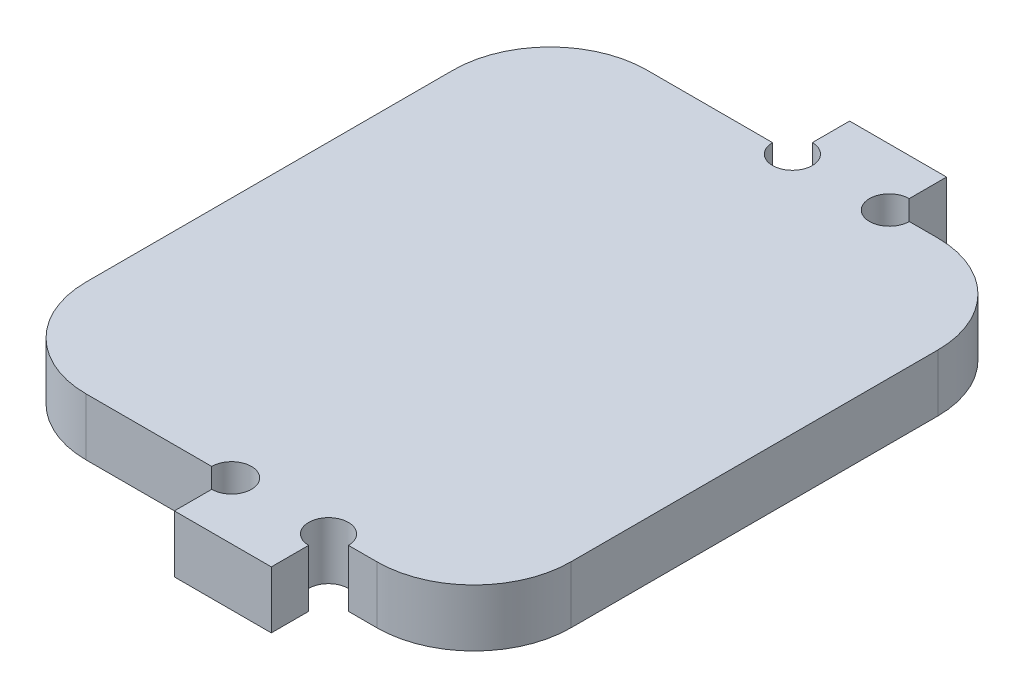
from build123d import *

# Parameters (mm, degrees)
SKETCH1_W           = 10
SKETCH1_H           = 5.9
BOSS_EXTRUDE1_DEPTH = 5.9
FILLET1_R           = 10
CUT_EXTRUDE1_REACH  = 7.9
SKETCH2_R           = 2.05


with BuildPart() as part:
    # Sketch1 → Boss-Extrude1 (new body)
    with BuildSketch(Plane(origin=(0, 0, 0), x_dir=(1, 0, 0), z_dir=(0, 1, 0))):
        Polygon((-25, 28.925), (-25, -28.925), (0, -28.925), (0, -23.025), (10, -23.025), (10, -28.925), (25, -28.925), (25, 28.925), (10, 28.925), (10, 23.025), (0, 23.025), (0, 28.925), align=None)
        with Locations((5, -25.975)):
            Rectangle(SKETCH1_W, SKETCH1_H)
        with Locations((5, -31.875)):
            Rectangle(SKETCH1_W, SKETCH1_H)
        with Locations((5, 25.975)):
            Rectangle(SKETCH1_W, SKETCH1_H)
        with Locations((5, 31.875)):
            Rectangle(SKETCH1_W, SKETCH1_H)
    extrude(amount=BOSS_EXTRUDE1_DEPTH)

    # Fillet1
    fillet1_edges = [part.edges().sort_by_distance(p)[0] for p in [
        (25, 2.95, -28.925),
        (25, 2.95, 28.925),
        (-25, 2.95, 28.925),
        (-25, 2.95, -28.925),
    ]]
    fillet(fillet1_edges, radius=FILLET1_R)

    # Sketch2 → Cut-Extrude1 (cut, up to next)
    with BuildSketch(Plane(origin=(0, 5.9, 0), x_dir=(1, 0, 0), z_dir=(0, 1, 0)), mode=Mode.PRIVATE) as cut_extrude1_sk1:
        with Locations((0, 28.925)):
            Circle(SKETCH2_R)
    cut_extrude1_tool1 = extrude(cut_extrude1_sk1.sketch, amount=-CUT_EXTRUDE1_REACH, mode=Mode.PRIVATE) & part.part
    add(cut_extrude1_tool1.solids().sort_by_distance((0, 5.9, -28.925))[0], mode=Mode.SUBTRACT)
    # Sketch2 → Cut-Extrude1 (cut, up to next)
    with BuildSketch(Plane(origin=(0, 5.9, 0), x_dir=(1, 0, 0), z_dir=(0, 1, 0)), mode=Mode.PRIVATE) as cut_extrude1_sk2:
        with Locations((10, 28.925)):
            Circle(SKETCH2_R)
    cut_extrude1_tool2 = extrude(cut_extrude1_sk2.sketch, amount=-CUT_EXTRUDE1_REACH, mode=Mode.PRIVATE) & part.part
    add(cut_extrude1_tool2.solids().sort_by_distance((10, 5.9, -28.925))[0], mode=Mode.SUBTRACT)
    # Sketch2 → Cut-Extrude1 (cut, up to next)
    with BuildSketch(Plane(origin=(0, 5.9, 0), x_dir=(1, 0, 0), z_dir=(0, 1, 0)), mode=Mode.PRIVATE) as cut_extrude1_sk3:
        with Locations((0, -28.925)):
            Circle(SKETCH2_R)
    cut_extrude1_tool3 = extrude(cut_extrude1_sk3.sketch, amount=-CUT_EXTRUDE1_REACH, mode=Mode.PRIVATE) & part.part
    add(cut_extrude1_tool3.solids().sort_by_distance((0, 5.9, 28.925))[0], mode=Mode.SUBTRACT)
    # Sketch2 → Cut-Extrude1 (cut, up to next)
    with BuildSketch(Plane(origin=(0, 5.9, 0), x_dir=(1, 0, 0), z_dir=(0, 1, 0)), mode=Mode.PRIVATE) as cut_extrude1_sk4:
        with Locations((10, -28.925)):
            Circle(SKETCH2_R)
    cut_extrude1_tool4 = extrude(cut_extrude1_sk4.sketch, amount=-CUT_EXTRUDE1_REACH, mode=Mode.PRIVATE) & part.part
    add(cut_extrude1_tool4.solids().sort_by_distance((10, 5.9, 28.925))[0], mode=Mode.SUBTRACT)


solid = part.part
